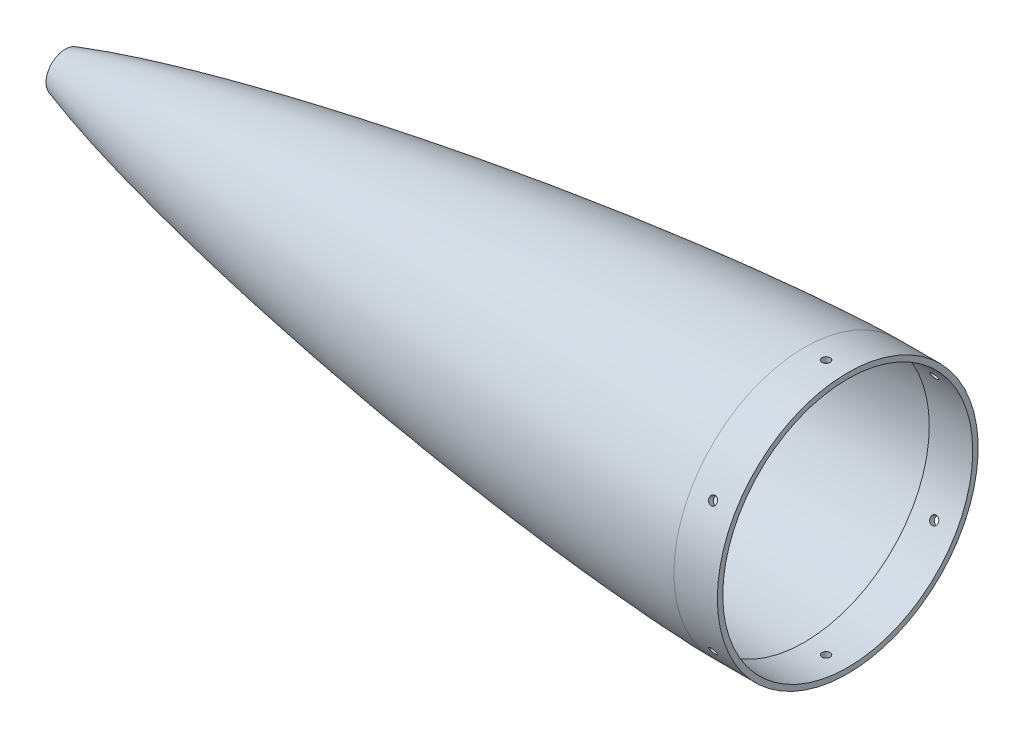
from build123d import *

# Parameters (mm, degrees)
SKETCH7_R          = 152.4
CUT_EXTRUDE1_DEPTH = 147.399141516
SKETCH17_R         = 4.7625
CUT_EXTRUDE4_DEPTH = 147.399141516
CIRPATTERN2_COUNT  = 6


with BuildPart() as part:
    # Sketch6 → Revolve1 (revolve)
    with BuildSketch(Plane.XY, mode=Mode.PRIVATE) as revolve1_sk:
        with BuildLine():
            Line((50.8, 22.53035676), (50.8, 6.35))
            Line((50.8, 6.35), (53.975, 6.35))
            Line((53.975, 6.35), (53.975, 20.227565916))
            add(Edge.make_bspline(
                [(53.975, 20.227565916), (54.291634879, 20.330430839), (55.162475518, 20.612719168), (56.636149311, 21.087725347), (58.867170376, 21.80102074), (61.522421046, 22.638682883), (64.736507837, 23.637812157), (68.023541536, 24.646609183), (72.39438926, 25.969741612), (77.802325895, 27.573199633), (84.37229967, 29.477097548), (93.118193973, 31.954107645), (108.466778526, 36.165197289), (130.491628823, 41.875745108), (165.870302673, 50.489926314), (210.303076361, 60.449379541), (281.693068548, 75.067985253), (371.347473816, 91.310304544), (479.374979471, 108.229836311), (569.684892552, 120.376775068), (642.076792345, 128.912483065), (696.438363769, 134.692640498), (750.863527692, 139.800693107), (796.267539796, 143.42521879), (832.617797313, 145.860290015), (859.890749047, 147.416222506), (882.628689993, 148.436275801), (898.53412358, 148.946546098), (907.62769622, 149.150954449), (912.14731785, 149.217348506), (914.4107585, 149.225018228)],
                knots=[0.06148136, 0.06148136, 0.06148136, 0.06148136, 0.06256458, 0.064402689, 0.066240798, 0.069917015, 0.073593232, 0.07726945, 0.080945667, 0.088298102, 0.095650536, 0.103002971, 0.11770784, 0.147117579, 0.176527318, 0.235346795, 0.294166272, 0.411805227, 0.529444182, 0.647083136, 0.705902613, 0.764722091, 0.823541568, 0.882361045, 0.911770784, 0.941180523, 0.970590261, 0.985295131, 0.992647565, 1, 1, 1, 1], degree=3))
            Line((914.4107585, 149.225018228), (914.4107585, 146.05))
            Line((914.4107585, 146.05), (1066.8, 146.05))
            Line((1066.8, 146.05), (1066.8, 149.225))
            Line((1066.8, 149.225), (965.2, 149.225))
            Line((965.2, 149.225), (965.2, 152.4))
            Line((965.2, 152.4), (914.4, 152.4))
            add(Edge.make_bspline(
                [(50.8, 22.53035676), (51.62596102, 22.801930188), (53.247366667, 23.331443773), (57.113810342, 24.581671091), (62.137627853, 26.163245596), (68.472923462, 28.113411094), (76.389796689, 30.474842786), (85.386033894, 33.081102875), (95.241355255, 35.841520364), (106.104903016, 38.788706559), (117.812200959, 41.867831442), (130.423899043, 45.08497442), (143.907449646, 48.417167108), (158.285989872, 51.860839853), (172.682057827, 55.208017205), (187.101006341, 58.468808185), (201.536340401, 61.648015415), (215.98908439, 64.751824582), (234.073297096, 68.542392147), (255.802551989, 72.956576003), (281.189453131, 77.92470015), (306.614812158, 82.692611325), (328.432361696, 86.646151134), (350.268122203, 90.497714312), (372.121192631, 94.250003895), (397.640090518, 98.488121242), (426.834492226, 103.147632175), (456.056824987, 107.628600482), (485.305388678, 111.934967932), (514.578772116, 116.069226586), (543.875783343, 120.032588186), (573.19542697, 123.82488003), (602.536868801, 127.444739672), (631.89942018, 130.889153604), (661.282519219, 134.153873932), (698.036524214, 138.001817701), (742.180870702, 142.229994267), (786.373789985, 145.926990276), (830.615211008, 148.98950394), (864.145536025, 150.817451898), (884.93243709, 151.702539519), (900.347440379, 152.177178216), (908.376949057, 152.340862845), (912.39222778, 152.393196617), (914.4, 152.4)],
                knots=[0.058888363, 0.058888363, 0.058888363, 0.058888363, 0.058888363, 0.06286181, 0.066835256, 0.074782149, 0.082729042, 0.090675935, 0.102752696, 0.114829458, 0.126906219, 0.138982981, 0.154876753, 0.170770526, 0.186664299, 0.202558071, 0.218451844, 0.234345618, 0.250239391, 0.266133165, 0.297920711, 0.329708258, 0.361495805, 0.377389579, 0.393283353, 0.4250709, 0.456858447, 0.488645994, 0.52043354, 0.552221087, 0.584008633, 0.615796181, 0.647583729, 0.679371276, 0.711158823, 0.74294637, 0.774733917, 0.838309011, 0.901884107, 0.933671654, 0.965459201, 0.9827296, 0.9913648, 1, 1, 1, 1, 1], degree=4))
        make_face()
    revolve(revolve1_sk.sketch.rotate(Axis((-61.64472501, 0, 0), (1, 0, 0)), 90), axis=Axis((-61.64472501, 0, 0), (1, 0, 0)))

    # Sketch7 → Cut-Extrude1 (cut)
    with BuildSketch(Plane(origin=(965.2, 0, 0), x_dir=(0, 0, -1), z_dir=(1, 0, 0))):
        with Locations(Location((0, 0, 0), (0, 0, 180))):
            Circle(SKETCH7_R)
    extrude(amount=CUT_EXTRUDE1_DEPTH, mode=Mode.SUBTRACT)

    # Sketch17 → Cut-Extrude4 (cut)
    with BuildSketch(Plane(origin=(0, 152.4, 0), x_dir=(1, 0, 0), z_dir=(0, 1, 0))):
        with Locations(Location((939.8, 0, 0), (0, 0, 270))):
            Circle(SKETCH17_R)
    cut_extrude4 = extrude(amount=-CUT_EXTRUDE4_DEPTH, mode=Mode.SUBTRACT)

    # CirPattern2: Cut-Extrude4 ×6 about axis
    cirpattern2_axis = Axis((0, 0, 0), (1, 0, 0))
    for i in range(1, CIRPATTERN2_COUNT):
        add(cut_extrude4.rotate(cirpattern2_axis, i * 360 / CIRPATTERN2_COUNT), mode=Mode.SUBTRACT)


solid = part.part
